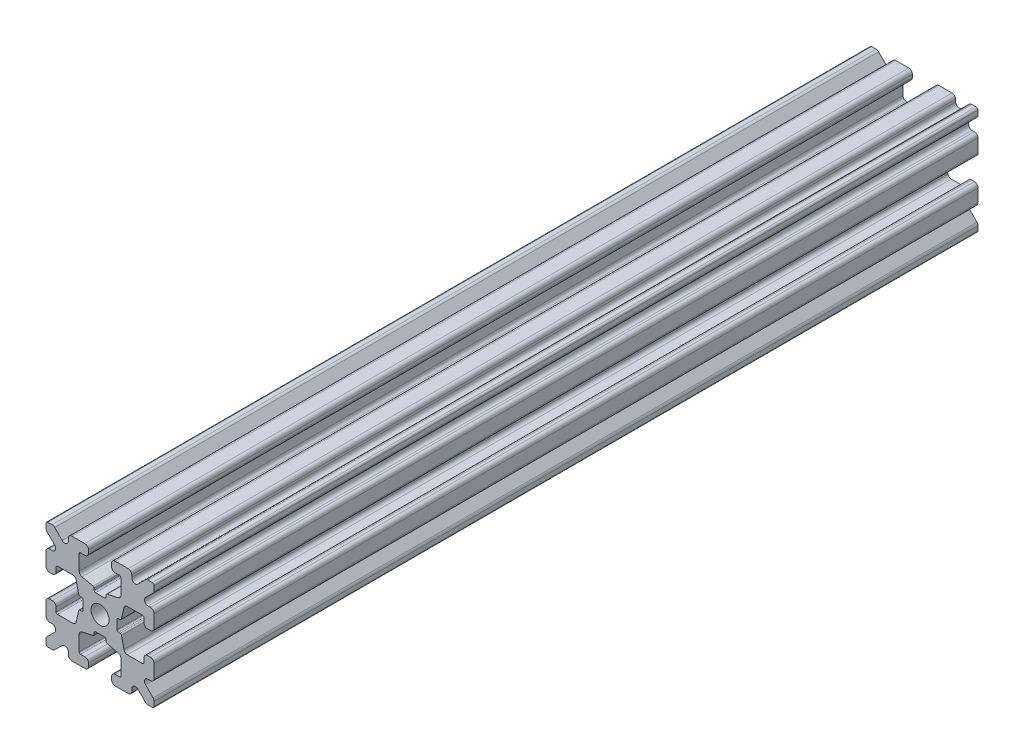
from build123d import *

# Parameters (mm, degrees)
SKETCH1_W           = 15
SKETCH1_H           = 15
SKETCH1_R           = 1.25
BOSS_EXTRUDE1_DEPTH = 57.15
FILLET1_R           = 0.25
CUT_EXTRUDE1_DEPTH  = 115.3
CUT_EXTRUDE3_DEPTH  = 115.3
FILLET3_R           = 0.5
FILLET4_R           = 0.5
FILLET5_R           = 3
FILLET6_R           = 0.2
CUT_EXTRUDE4_DEPTH  = 115.3
FILLET8_R           = 0.5
SKETCH6_W           = 5.1529354
SKETCH6_H           = 1.651
SKETCH6_W_2         = 1.651
SKETCH6_H_2         = 5.1529354
CUT_EXTRUDE5_DEPTH  = 115.3
FILLET10_R          = 0.2


with BuildPart() as part:
    # Sketch1 → Boss-Extrude1 (new body, symmetric)
    with BuildSketch(Plane.XY):
        Rectangle(SKETCH1_W, SKETCH1_H)
        Circle(SKETCH1_R, mode=Mode.SUBTRACT)
    extrude(amount=BOSS_EXTRUDE1_DEPTH, both=True)

    # Fillet1
    fillet1_edges = [part.edges().sort_by_distance(p)[0] for p in [
        (7.5, -7.5, 0),
        (-7.5, -7.5, 0),
        (-7.5, 7.5, 0),
        (7.5, 7.5, 0),
    ]]
    fillet(fillet1_edges, radius=FILLET1_R)

    # Sketch2 → Cut-Extrude1 (cut, through all)
    with BuildSketch(Plane.XY.offset(57.15)):
        Polygon((-7.5, 1.6), (-6.1, 1.6), (-6.1, 2.9), (-3.4, 2.9), (-3.4, -2.9), (-6.1, -2.9), (-6.1, -1.6), (-7.5, -1.6), align=None)
        Polygon((2.9, 6.1), (1.6, 6.1), (1.6, 7.5), (-1.6, 7.5), (-1.6, 6.1), (-2.9, 6.1), (-2.9, 3.4), (2.9, 3.4), align=None)
        Polygon((-1.6, -7.5), (-1.6, -6.1), (-2.9, -6.1), (-2.9, -3.4), (2.9, -3.4), (2.9, -6.1), (1.6, -6.1), (1.6, -7.5), align=None)
        Polygon((6.1, -2.9), (6.1, -1.6), (7.5, -1.6), (7.5, 1.6), (6.1, 1.6), (6.1, 2.9), (3.4, 2.9), (3.4, -2.9), align=None)
    extrude(amount=-CUT_EXTRUDE1_DEPTH, mode=Mode.SUBTRACT)

    # Sketch4 → Cut-Extrude3 (cut, through all)
    with BuildSketch(Plane.XY.offset(57.15)):
        Polygon((-3.4, 2.9), (-2.75, 0), (-3.4, -2.9), align=None)
        Polygon((-2.9, 3.4), (0, 2.75), (2.9, 3.4), align=None)
        Polygon((3.4, 2.9), (2.75, 0), (3.4, -2.9), align=None)
        Polygon((-2.9, -3.4), (0, -2.75), (2.9, -3.4), align=None)
    extrude(amount=-CUT_EXTRUDE3_DEPTH, mode=Mode.SUBTRACT)

    # Fillet3
    fillet3_edges = [part.edges().sort_by_distance(p)[0] for p in [
        (1.6, -7.5, 0),
        (-1.6, -7.5, 0),
        (-1.6, -6.1, 0),
        (1.6, -6.1, 0),
        (6.1, 1.6, 0),
        (7.5, 1.6, 0),
        (7.5, -1.6, 0),
        (6.1, -1.6, 0),
        (-7.5, -1.6, 0),
        (-7.5, 1.6, 0),
        (-6.1, 1.6, 0),
        (-6.1, -1.6, 0),
        (-1.6, 6.1, 0),
        (-1.6, 7.5, 0),
        (1.6, 7.5, 0),
        (1.6, 6.1, 0),
    ]]
    fillet(fillet3_edges, radius=FILLET3_R)

    # Fillet4
    fillet4_edges = [part.edges().sort_by_distance(p)[0] for p in [
        (-2.9, -3.4, 0),
        (2.9, -3.4, 0),
        (3.4, -2.9, 0),
        (3.4, 2.9, 0),
        (-3.4, 2.9, 0),
        (-3.4, -2.9, 0),
        (2.9, 3.4, 0),
        (-2.9, 3.4, 0),
    ]]
    fillet(fillet4_edges, radius=FILLET4_R)

    # Fillet5
    fillet5_edges = [part.edges().sort_by_distance(p)[0] for p in [
        (-2.75, 0, 0),
        (0, 2.75, 0),
        (2.75, 0, 0),
        (0, -2.75, 0),
    ]]
    fillet(fillet5_edges, radius=FILLET5_R)

    # Fillet6
    fillet6_edges = [part.edges().sort_by_distance(p)[0] for p in [
        (-2.9, -6.1, 0),
        (2.9, -6.1, 0),
        (6.1, -2.9, 0),
        (6.1, 2.9, 0),
        (-6.1, 2.9, 0),
        (-6.1, -2.9, 0),
        (2.9, 6.1, 0),
        (-2.9, 6.1, 0),
    ]]
    fillet(fillet6_edges, radius=FILLET6_R)

    # Sketch5 → Cut-Extrude4 (cut, through all)
    with BuildSketch(Plane.XY.offset(57.15)):
        Polygon((-7.5, 6.439339828), (-5.460660172, 4.4), (-7.5, 4.4), align=None)
        Polygon((-6.439339828, 7.5), (-4.4, 5.460660172), (-4.4, 7.5), align=None)
        Polygon((4.4, 7.5), (6.439339828, 7.5), (4.4, 5.460660172), align=None)
        Polygon((7.5, 6.439339828), (7.5, 4.4), (5.460660172, 4.4), align=None)
        Polygon((7.5, -6.439339828), (5.460660172, -4.4), (7.5, -4.4), align=None)
        Polygon((6.439339828, -7.5), (4.4, -5.460660172), (4.4, -7.5), align=None)
        Polygon((-4.4, -7.5), (-6.439339828, -7.5), (-4.4, -5.460660172), align=None)
        Polygon((-7.5, -6.439339828), (-7.5, -4.4), (-5.460660172, -4.4), align=None)
    extrude(amount=-CUT_EXTRUDE4_DEPTH, mode=Mode.SUBTRACT)

    # Fillet8
    fillet8_edges = [part.edges().sort_by_distance(p)[0] for p in [
        (-7.5, 4.4, 0),
        (-7.5, 6.439339828, 0),
        (-5.460660172, 4.4, 0),
        (7.5, -4.4, 0),
        (7.5, -6.439339828, 0),
        (5.460660172, -4.4, 0),
        (5.460660172, 4.4, 0),
        (7.5, 6.439339828, 0),
        (7.5, 4.4, 0),
        (-4.4, 7.5, 0),
        (-4.4, 5.460660172, 0),
        (-6.439339828, 7.5, 0),
        (-5.460660172, -4.4, 0),
        (-7.5, -6.439339828, 0),
        (-7.5, -4.4, 0),
        (4.4, 5.460660172, 0),
        (4.4, 7.5, 0),
        (6.439339828, 7.5, 0),
        (6.439339828, -7.5, 0),
        (4.4, -7.5, 0),
        (4.4, -5.460660172, 0),
        (-6.439339828, -7.5, 0),
        (-4.4, -5.460660172, 0),
        (-4.4, -7.5, 0),
    ]]
    fillet(fillet8_edges, radius=FILLET8_R)

    # Sketch6 → Cut-Extrude5 (cut, through all)
    with BuildSketch(Plane.XY.offset(57.15)):
        with Locations((4.9235323, 0)):
            Rectangle(SKETCH6_W, SKETCH6_H)
        with Locations((0, -4.9235323)):
            Rectangle(SKETCH6_W_2, SKETCH6_H_2)
        with Locations((-4.9235323, 0)):
            Rectangle(SKETCH6_W, SKETCH6_H)
        with Locations((0, 4.9235323)):
            Rectangle(SKETCH6_W_2, SKETCH6_H_2)
    extrude(amount=-CUT_EXTRUDE5_DEPTH, mode=Mode.SUBTRACT)

    # Fillet10
    fillet10_edges = [part.edges().sort_by_distance(p)[0] for p in [
        (0.8255, -2.935025862, 0),
        (-0.8255, -2.935025862, 0),
        (0.8255, -2.3470646, 0),
        (-0.8255, -2.3470646, 0),
        (2.935025862, 0.8255, 0),
        (2.935025862, -0.8255, 0),
        (2.3470646, 0.8255, 0),
        (2.3470646, -0.8255, 0),
        (-2.935025862, -0.8255, 0),
        (-2.935025862, 0.8255, 0),
        (-2.3470646, -0.8255, 0),
        (-2.3470646, 0.8255, 0),
        (-0.8255, 2.935025862, 0),
        (0.8255, 2.935025862, 0),
        (-0.8255, 2.3470646, 0),
        (0.8255, 2.3470646, 0),
    ]]
    fillet(fillet10_edges, radius=FILLET10_R)


solid = part.part
